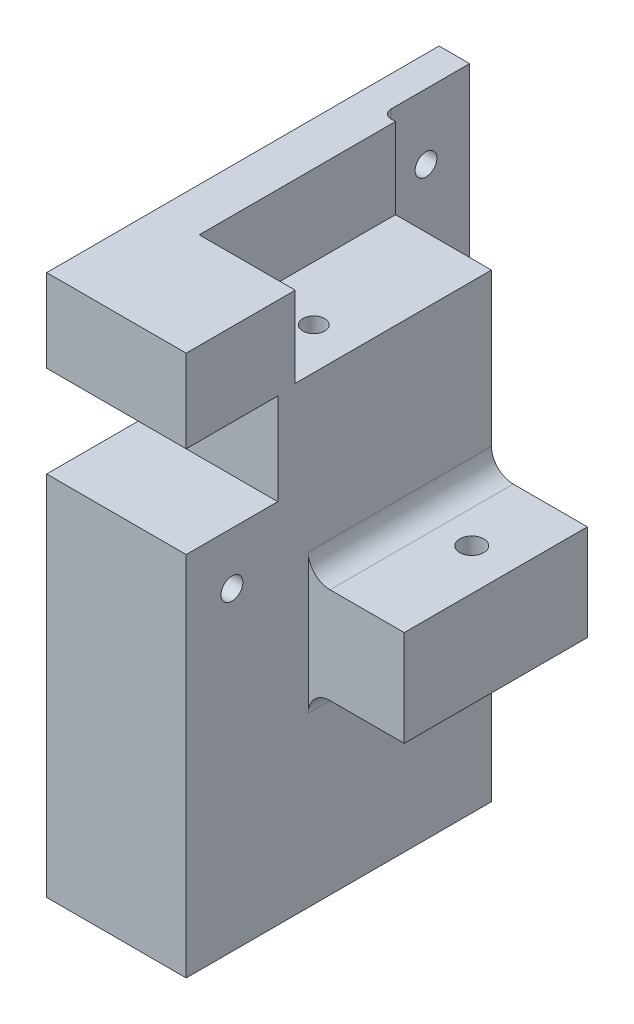
from build123d import *

# Parameters (mm, degrees)
SKETCH1_W                = 32
SKETCH1_H                = 70
BOSS_EXTRUDE1_DEPTH      = 40
BOSS_EXTRUDE1_DEPTH_BACK = 84.1
SKETCH2_W                = 21
SKETCH2_H                = 21
CUT_EXTRUDE1_DEPTH       = 17
CUT_EXTRUDE1_DEPTH_BACK  = 17
CUT_EXTRUDE2_START       = -18.5
SKETCH3_W                = 22
SKETCH3_H                = 45
CUT_EXTRUDE2_DEPTH       = 18.5
SKETCH4_W                = 42
SKETCH4_H                = 22
BOSS_EXTRUDE2_DEPTH      = 22
SKETCH5_R                = 2.75
CUT_EXTRUDE3_DEPTH       = 66.6
SKETCH6_W                = 7
SKETCH6_H                = 65
BOSS_EXTRUDE3_DEPTH      = 20
SKETCH7_R                = 2.5
CUT_EXTRUDE4_DEPTH       = 17
CUT_EXTRUDE4_DEPTH_BACK  = 39
SKETCH8_R                = 2.5
CUT_EXTRUDE5_DEPTH       = 8
FILLET1_R                = 2
FILLET2_R                = 5
SKETCH9_R                = 2.5
CUT_EXTRUDE6_DEPTH       = 47.45


with BuildPart() as part:
    # Sketch1 → Boss-Extrude1 (new body, two sides)
    with BuildSketch(Plane(origin=(0, 0, 0), x_dir=(1, 0, 0), z_dir=(0, 1, 0))) as boss_extrude1_sk:
        Rectangle(SKETCH1_W, SKETCH1_H)
    extrude(amount=BOSS_EXTRUDE1_DEPTH)
    extrude(boss_extrude1_sk.sketch, amount=-BOSS_EXTRUDE1_DEPTH_BACK)

    # Sketch2 → Cut-Extrude1 (cut, two sides)
    with BuildSketch(Plane(origin=(0, 0, 0), x_dir=(0, 0, -1), z_dir=(1, 0, 0))) as cut_extrude1_sk:
        with Locations((-24.5, 10.5)):
            Rectangle(SKETCH2_W, SKETCH2_H)
    extrude(amount=CUT_EXTRUDE1_DEPTH, mode=Mode.SUBTRACT)
    extrude(cut_extrude1_sk.sketch, amount=-CUT_EXTRUDE1_DEPTH_BACK, mode=Mode.SUBTRACT)

    # Sketch3 → Cut-Extrude2 (cut)
    with BuildSketch(Plane(origin=(0, 40, 0), x_dir=(1, 0, 0), z_dir=(0, 1, 0)).offset(CUT_EXTRUDE2_START)):
        with Locations((5, 12.5)):
            Rectangle(SKETCH3_W, SKETCH3_H)
    extrude(amount=CUT_EXTRUDE2_DEPTH, mode=Mode.SUBTRACT)

    # Sketch4 → Boss-Extrude2 (add)
    with BuildSketch(Plane(origin=(16, 0, 0), x_dir=(0, 0, -1), z_dir=(1, 0, 0))):
        with Locations((14, -29.5)):
            Rectangle(SKETCH4_W, SKETCH4_H)
    extrude(amount=BOSS_EXTRUDE2_DEPTH)

    # Sketch5 → Cut-Extrude3 (cut, through all)
    with BuildSketch(Plane(origin=(0, -18.5, 0), x_dir=(1, 0, 0), z_dir=(0, 1, 0))):
        with Locations((28.5, 18)):
            Circle(SKETCH5_R)
    extrude(amount=-CUT_EXTRUDE3_DEPTH, mode=Mode.SUBTRACT)

    # Sketch6 → Boss-Extrude3 (add)
    with BuildSketch(Plane.XY.offset(-35)):
        with Locations((-12.5, 7.5)):
            Rectangle(SKETCH6_W, SKETCH6_H)
    extrude(amount=-BOSS_EXTRUDE3_DEPTH)

    # Sketch7 → Cut-Extrude4 (cut, two sides)
    with BuildSketch(Plane.ZY) as cut_extrude4_sk:
        with Locations((24.5, -12)):
            Circle(SKETCH7_R)
    extrude(amount=CUT_EXTRUDE4_DEPTH, mode=Mode.SUBTRACT)
    extrude(cut_extrude4_sk.sketch, amount=-CUT_EXTRUDE4_DEPTH_BACK, mode=Mode.SUBTRACT)

    # Sketch8 → Cut-Extrude5 (cut, through all)
    with BuildSketch(Plane(origin=(-9, 0, 0), x_dir=(0, 0, -1), z_dir=(1, 0, 0))):
        with Locations((45, 25)):
            Circle(SKETCH8_R)
        with Locations((45, -10)):
            Circle(SKETCH8_R)
    extrude(amount=-CUT_EXTRUDE5_DEPTH, mode=Mode.SUBTRACT)

    # Fillet1
    fillet1_edges = [part.edges().sort_by_distance(p)[0] for p in [
        (-9, 7.5, -35),
    ]]
    fillet(fillet1_edges, radius=FILLET1_R)

    # Fillet2
    fillet2_edges = [part.edges().sort_by_distance(p)[0] for p in [
        (16, -18.5, -14),
        (16, -40.5, -14),
        (-12.5, -25, -35),
    ]]
    fillet(fillet2_edges, radius=FILLET2_R)

    # Sketch9 → Cut-Extrude6 (cut)
    with BuildSketch(Plane(origin=(0, 21.5, 0), x_dir=(1, 0, 0), z_dir=(0, 1, 0))):
        with Locations((6.5, 3.75)):
            Circle(SKETCH9_R)
    extrude(amount=-CUT_EXTRUDE6_DEPTH, mode=Mode.SUBTRACT)


solid = part.part
